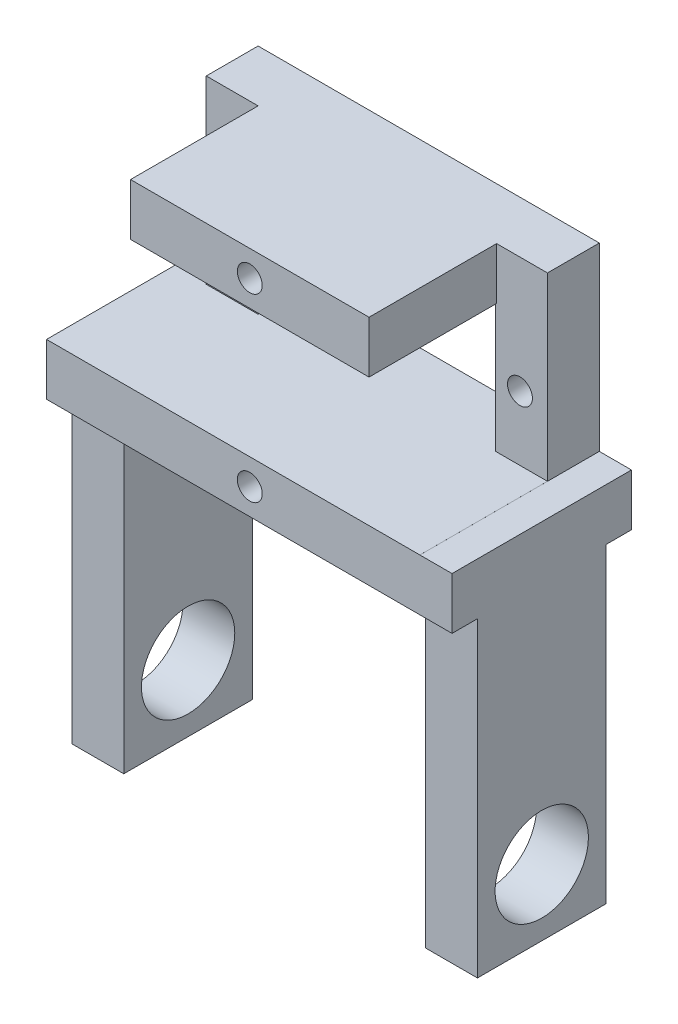
from build123d import *

# Parameters (mm, degrees)
SKETCH1_W           = 32.9
SKETCH1_H           = 22.4
BOSS_EXTRUDE1_DEPTH = 5
SKETCH2_R           = 1.2
SKETCH2_W           = 22.9
SKETCH2_H           = 12.4
CUT_EXTRUDE2_DEPTH  = 5
SKETCH3_W           = 22.996888994
SKETCH3_H           = 5
BOSS_EXTRUDE2_DEPTH = 12.3
SKETCH4_R           = 1.2
CUT_EXTRUDE3_DEPTH  = 5
SKETCH6_W           = 5
SKETCH6_H           = 5
SKETCH6_W_2         = 4.903111006
BOSS_EXTRUDE3_DEPTH = 12.3
SKETCH8_W           = 17.3
SKETCH8_H           = 4.998204887
BOSS_EXTRUDE4_DEPTH = 3.1
SKETCH9_W           = 17.3
SKETCH9_H           = 5
BOSS_EXTRUDE5_DEPTH = 3.1
SKETCH18_W          = 5
SKETCH18_H          = 12.4
BOSS_EXTRUDE7_DEPTH = 30
SKETCH19_R          = 4.5
CUT_EXTRUDE6_DEPTH  = 30
SKETCH20_R          = 4.5
CUT_EXTRUDE7_DEPTH  = 30
SKETCH10_W          = 5
SKETCH10_H          = 12.4
BOSS_EXTRUDE6_DEPTH = 30
SKETCH21_R          = 4.5
CUT_EXTRUDE8_DEPTH  = 10
SKETCH22_R          = 4.5
CUT_EXTRUDE9_DEPTH  = 10


with BuildPart() as part:
    # Sketch1 → Boss-Extrude1 (new body)
    with BuildSketch(Plane.XY):
        Rectangle(SKETCH1_W, SKETCH1_H)
    extrude(amount=BOSS_EXTRUDE1_DEPTH)

    # Sketch2 → Cut-Extrude2 (cut)
    with BuildSketch(Plane.XY.offset(5)):
        with Locations((13.8, 0)):
            Circle(SKETCH2_R)
        with Locations((-13.8, 0)):
            Circle(SKETCH2_R)
        Rectangle(SKETCH2_W, SKETCH2_H)
    extrude(amount=-CUT_EXTRUDE2_DEPTH, mode=Mode.SUBTRACT)

    # Sketch3 → Boss-Extrude2 (add)
    with BuildSketch(Plane.XY.offset(5)):
        with Locations((0.048444497, 8.7)):
            Rectangle(SKETCH3_W, SKETCH3_H)
        with Locations((0.048444497, -8.7)):
            Rectangle(SKETCH3_W, SKETCH3_H)
    extrude(amount=BOSS_EXTRUDE2_DEPTH)

    # Sketch4 → Cut-Extrude3 (cut)
    with BuildSketch(Plane.XY.offset(17.3)):
        with Locations((0.048444497, 8.7)):
            Circle(SKETCH4_R)
        with Locations((0.048444497, -8.7)):
            Circle(SKETCH4_R)
    extrude(amount=-CUT_EXTRUDE3_DEPTH, mode=Mode.SUBTRACT)

    # Sketch6 → Boss-Extrude3 (add)
    with BuildSketch(Plane.XY.offset(5)):
        with Locations((-13.95, -8.7)):
            Rectangle(SKETCH6_W, SKETCH6_H)
        with Locations((13.998444497, -8.7)):
            Rectangle(SKETCH6_W_2, SKETCH6_H)
    extrude(amount=BOSS_EXTRUDE3_DEPTH)

    # Sketch8 → Boss-Extrude4 (add)
    with BuildSketch(Plane(origin=(16.45, 0, 0), x_dir=(0, 0, -1), z_dir=(1, 0, 0))):
        with Locations((-8.65, -8.700897557)):
            Rectangle(SKETCH8_W, SKETCH8_H)
    extrude(amount=BOSS_EXTRUDE4_DEPTH)

    # Sketch9 → Boss-Extrude5 (add)
    with BuildSketch(Plane.ZY.offset(16.45)):
        with Locations((8.65, -8.7)):
            Rectangle(SKETCH9_W, SKETCH9_H)
    extrude(amount=BOSS_EXTRUDE5_DEPTH)

    # Sketch18 → Boss-Extrude7 (add)
    with BuildSketch(Plane.XZ.offset(11.2)):
        with Locations((-17.05, 8.65)):
            Rectangle(SKETCH18_W, SKETCH18_H)
        with Locations((17.05, 8.65)):
            Rectangle(SKETCH18_W, SKETCH18_H)
    extrude(amount=BOSS_EXTRUDE7_DEPTH)

    # Sketch19 → Cut-Extrude6 (cut)
    with BuildSketch(Plane.ZY.offset(19.55)):
        with Locations((8.65, -34.8)):
            Circle(SKETCH19_R)
    extrude(amount=-CUT_EXTRUDE6_DEPTH, mode=Mode.SUBTRACT)

    # Sketch20 → Cut-Extrude7 (cut)
    with BuildSketch(Plane(origin=(19.55, 0, 0), x_dir=(0, 0, -1), z_dir=(1, 0, 0))):
        with Locations((-8.65, -34.8)):
            Circle(SKETCH20_R)
    extrude(amount=-CUT_EXTRUDE7_DEPTH, mode=Mode.SUBTRACT)

    # Sketch10 → Boss-Extrude6 (add)
    with BuildSketch(Plane.XZ.offset(11.2)):
        with Locations((17.05, 8.65)):
            Rectangle(SKETCH10_W, SKETCH10_H)
        with Locations((-17.05, 8.65)):
            Rectangle(SKETCH10_W, SKETCH10_H)
    extrude(amount=BOSS_EXTRUDE6_DEPTH)

    # Sketch21 → Cut-Extrude8 (cut)
    with BuildSketch(Plane(origin=(19.55, 0, 0), x_dir=(0, 0, -1), z_dir=(1, 0, 0))):
        with Locations((-8.65, -34.8)):
            Circle(SKETCH21_R)
    extrude(amount=-CUT_EXTRUDE8_DEPTH, mode=Mode.SUBTRACT)

    # Sketch22 → Cut-Extrude9 (cut)
    with BuildSketch(Plane(origin=(-14.55, 0, 0), x_dir=(0, 0, -1), z_dir=(1, 0, 0))):
        with Locations((-8.65, -34.8)):
            Circle(SKETCH22_R)
    extrude(amount=-CUT_EXTRUDE9_DEPTH, mode=Mode.SUBTRACT)


solid = part.part
